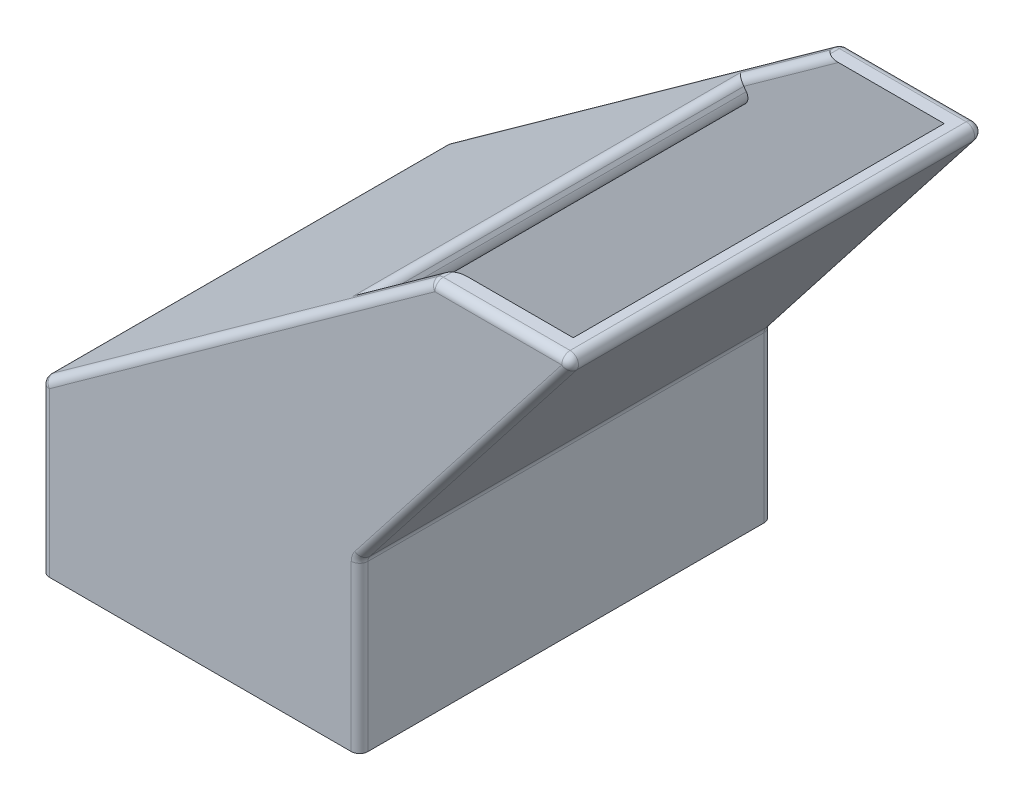
from build123d import *

# Parameters (mm, degrees)
SKETCH1_W               = 15.2
SKETCH1_H               = 19.7
EXTRUDE1_DEPTH          = 8
BOSS_EXTRUDE1_DEPTH     = 19.7
SHELL1_T                = -1
SKETCH5_R               = 0.5
EXTRUDE4_DEPTH          = 5
EXTRUDE7_DEPTH          = 10.85
EXTRUDE7_DEPTH_BACK     = 10.85
SKETCH14_W              = 17.7
SKETCH14_H              = 1
CUT_EXTRUDE1_DEPTH      = 6.686379255
CUT_EXTRUDE1_DEPTH_BACK = 5
FILLET1_R               = 0.4
FILLET3_R               = 0.4
FILLET4_R               = 5


with BuildPart() as part:
    # Sketch1 → Extrude1 (new body)
    with BuildSketch(Plane(origin=(0, 0, 0), x_dir=(1, 0, 0), z_dir=(0, 1, 0))):
        Rectangle(SKETCH1_W, SKETCH1_H)
    extrude(amount=EXTRUDE1_DEPTH)

    # Sketch11 → Boss-Extrude1 (add)
    with BuildSketch(Plane.XY.offset(9.85)):
        Polygon((-7.6, 8), (11.063283072, 21.398496459), (18.063283072, 21.398496459), (7.6, 8), align=None)
    extrude(amount=-BOSS_EXTRUDE1_DEPTH)

    # Shell1
    shell1_openings = [part.faces().sort_by_distance(p)[0] for p in [
        (14.563283072, 21.398496459, 0),
        (0, 0, 0),
    ]]
    offset(amount=SHELL1_T, openings=shell1_openings, kind=Kind.INTERSECTION)

    # Sketch5 → Extrude4 (add)
    with BuildSketch(Plane.XZ):
        with Locations((-7.6, 0)):
            Circle(SKETCH5_R)
    extrude(amount=-EXTRUDE4_DEPTH)

    # Sketch9 → Extrude7 (cut, two sides)
    with BuildSketch(Plane.XY) as extrude7_sk:
        Polygon((-7.6, 0), (-8.1, 1.2), (-8.1, 0), align=None)
    extrude(amount=EXTRUDE7_DEPTH, mode=Mode.SUBTRACT)
    extrude(extrude7_sk.sketch, amount=-EXTRUDE7_DEPTH_BACK, mode=Mode.SUBTRACT)

    # Sketch14 → Cut-Extrude1 (cut, two sides)
    with BuildSketch(Plane(origin=(17.4380235, 12.51887437, 0), x_dir=(0, 0, 1), z_dir=(0.812339894, 0.583184274, 0))) as cut_extrude1_sk:
        with Locations((0, -10.43091963)):
            Rectangle(SKETCH14_W, SKETCH14_H)
    extrude(amount=CUT_EXTRUDE1_DEPTH, mode=Mode.SUBTRACT)
    extrude(cut_extrude1_sk.sketch, amount=-CUT_EXTRUDE1_DEPTH_BACK, mode=Mode.SUBTRACT)

    # Fillet1
    fillet1_edges = [part.edges().sort_by_distance(p)[0] for p in [
        (7.6, 8, 0),
        (11.063283072, 21.398496459, -9.35),
        (18.063283072, 21.398496459, 0),
        (12.831641536, 14.699248229, 9.85),
        (14.563283072, 21.398496459, 9.85),
        (1.731641536, 14.699248229, 9.85),
        (1.731641536, 14.699248229, -9.85),
        (14.563283072, 21.398496459, -9.85),
        (12.831641536, 14.699248229, -9.85),
        (-7.6, 8, 0),
        (11.063283072, 21.398496459, 9.35),
        (9.032433338, 19.940535774, -8.85),
        (7.001583604, 18.482575089, 0),
        (9.032433338, 19.940535774, 8.85),
        (-7.6, 4, -9.85),
        (7.6, 4, -9.85),
        (7.6, 4, 9.85),
        (-7.6, 4, 9.85),
    ]]
    fillet(fillet1_edges, radius=FILLET1_R)

    # Fillet3
    fillet3_edges = [part.edges().sort_by_distance(p)[0] for p in [
        (7.584767878, 17.670235196, 0),
    ]]
    fillet(fillet3_edges, radius=FILLET3_R)

    # Fillet4
    fillet4_edges = [part.edges().sort_by_distance(p)[0] for p in [
        (-6.6, 7.48689492, 0),
        (6.6, 8.344203967, 0),
    ]]
    fillet(fillet4_edges, radius=FILLET4_R)


solid = part.part
